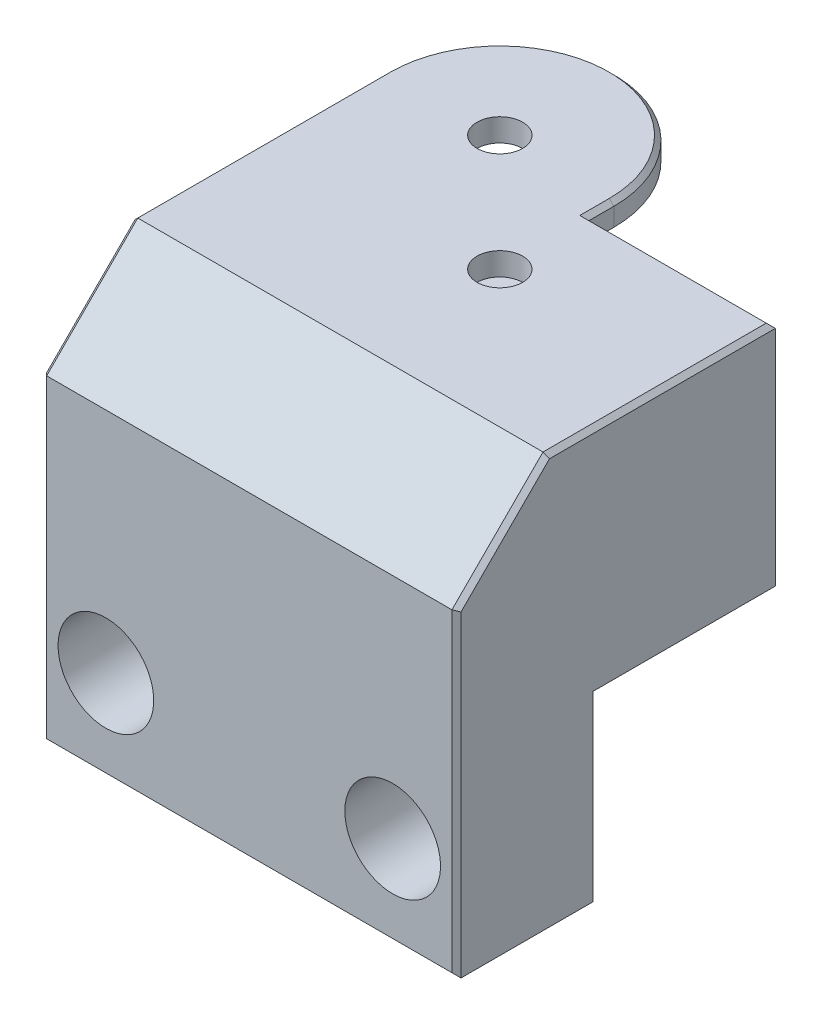
from build123d import *

# Parameters (mm, degrees)
SKETCH1_R                       = 2.5
BOSS_EXTRUDE1_DEPTH             = 25
SKETCH9_W                       = 45.48
SKETCH9_H                       = 45
BOSS_EXTRUDE4_DEPTH             = 15
CUT_EXTRUDE2_START              = -2.5
CUT_EXTRUDE2_DEPTH              = 19.5
SKETCH15_R                      = 2.5
BOSS_EXTRUDE5_DEPTH             = 25
CHAMFER1_SIZE                   = 10
CUT_EXTRUDE3_REACH              = 47.48
SKETCH16_W                      = 40
SKETCH16_H                      = 19.5
SKETCH17_W                      = 15.08
SKETCH17_H                      = 6
BOSS_EXTRUDE6_DEPTH             = 22
CBORE_FOR_M5_SBHCS1_D           = 5.5
CBORE_FOR_M5_SBHCS1_CBORE_D     = 10.5
CBORE_FOR_M5_SBHCS1_CBORE_DEPTH = 9.75
CHAMFER2_SIZE                   = 0.5


with BuildPart() as part:
    # Sketch1 → Boss-Extrude1 (new body)
    with BuildSketch(Plane(origin=(0, 0, 0), x_dir=(1, 0, 0), z_dir=(0, 1, 0))):
        Polygon((20.24, -10), (25.24, -10), (25.24, 10), (20.24, 10), (-20.24, 10), (-20.24, -10), align=None)
        Circle(SKETCH1_R, mode=Mode.SUBTRACT)
    extrude(amount=BOSS_EXTRUDE1_DEPTH)

    # Sketch9 → Boss-Extrude4 (add)
    with BuildSketch(Plane.XY.offset(10)):
        with Locations((2.5, 2.5)):
            Rectangle(SKETCH9_W, SKETCH9_H)
    extrude(amount=BOSS_EXTRUDE4_DEPTH)

    # Sketch10 → Cut-Extrude2 (cut)
    with BuildSketch(Plane(origin=(0, 25, 0), x_dir=(1, 0, 0), z_dir=(0, 1, 0)).offset(CUT_EXTRUDE2_START)):
        with BuildLine():
            Line((10.16, 0), (10.16, 10))
            Line((10.16, 10), (-10.16, 10))
            Line((-10.16, 10), (-10.16, 0))
            ThreePointArc((-10.16, 0), (0, -10.16), (10.16, 0))
        make_face()
    extrude(amount=-CUT_EXTRUDE2_DEPTH, mode=Mode.SUBTRACT)

    # Sketch15 → Boss-Extrude5 (add)
    with BuildSketch(Plane(origin=(0, 25, 0), x_dir=(1, 0, 0), z_dir=(0, 1, 0))):
        with BuildLine():
            Line((25.24, 10), (25.24, 12.732395665))
            ThreePointArc((25.24, 12.732395665), (12.732395665, 25.24), (0.224791329, 12.732395665))
            Line((0.224791329, 12.732395665), (0.224791329, 10))
            Line((0.224791329, 10), (25.24, 10))
        make_face()
        with Locations((12.732395665, 12.732395665)):
            Circle(SKETCH15_R, mode=Mode.SUBTRACT)
    extrude(amount=-BOSS_EXTRUDE5_DEPTH)

    # Chamfer1
    chamfer1_edges = [part.edges().sort_by_distance(p)[0] for p in [
        (2.5, 25, 25),
    ]]
    chamfer(chamfer1_edges, length=CHAMFER1_SIZE)

    # Sketch16 → Cut-Extrude3 (cut, up to next)
    with BuildSketch(Plane(origin=(25.24, 0, 0), x_dir=(0, 0, -1), z_dir=(1, 0, 0)), mode=Mode.PRIVATE) as cut_extrude3_sk1:
        with Locations((9.84, 12.75)):
            Rectangle(SKETCH16_W, SKETCH16_H)
    cut_extrude3_tool1 = extrude(cut_extrude3_sk1.sketch, amount=-CUT_EXTRUDE3_REACH, mode=Mode.PRIVATE) & part.part
    add(cut_extrude3_tool1.solids().sort_by_distance((25.24, 12.75, -9.84))[0], mode=Mode.SUBTRACT)

    # Sketch17 → Boss-Extrude6 (add)
    with BuildSketch(Plane(origin=(0, 25, 0), x_dir=(1, 0, 0), z_dir=(0, 1, 0))):
        with Locations((17.7, 0)):
            Rectangle(SKETCH17_W, SKETCH17_H)
    extrude(amount=-BOSS_EXTRUDE6_DEPTH)

    # CBORE for M5 SBHCS1 (through all)
    with Locations(Plane.XY.offset(25)):
        with Locations((-13.24, -10), (18.24, -10)):
            CounterBoreHole(CBORE_FOR_M5_SBHCS1_D / 2, CBORE_FOR_M5_SBHCS1_CBORE_D / 2, CBORE_FOR_M5_SBHCS1_CBORE_DEPTH)


with BuildPart() as body_2:
    # Mirror1: mirrored copy
    add(part.part.mirror(Plane(origin=(25.24, 25, 10), x_dir=(0, 0, 1), z_dir=(-1, 0, 0))))

    # Chamfer2
    chamfer2_edges = [body_2.edges().sort_by_distance(p)[0] for p in [
        (70.72, 25, 2.5),
        (47.98, -20, 25),
        (25.24, -2.5, 25),
        (60.487604335, 25, -10),
        (37.747604335, 25, -25.24),
        (50.255208671, 25, -11.366197832),
        (70.72, -2.5, 25),
        (70.72, 20, 20),
        (25.24, 25, 1.133802168),
        (25.24, 20, 20),
    ]]
    chamfer(chamfer2_edges, length=CHAMFER2_SIZE)


solid = body_2.part
